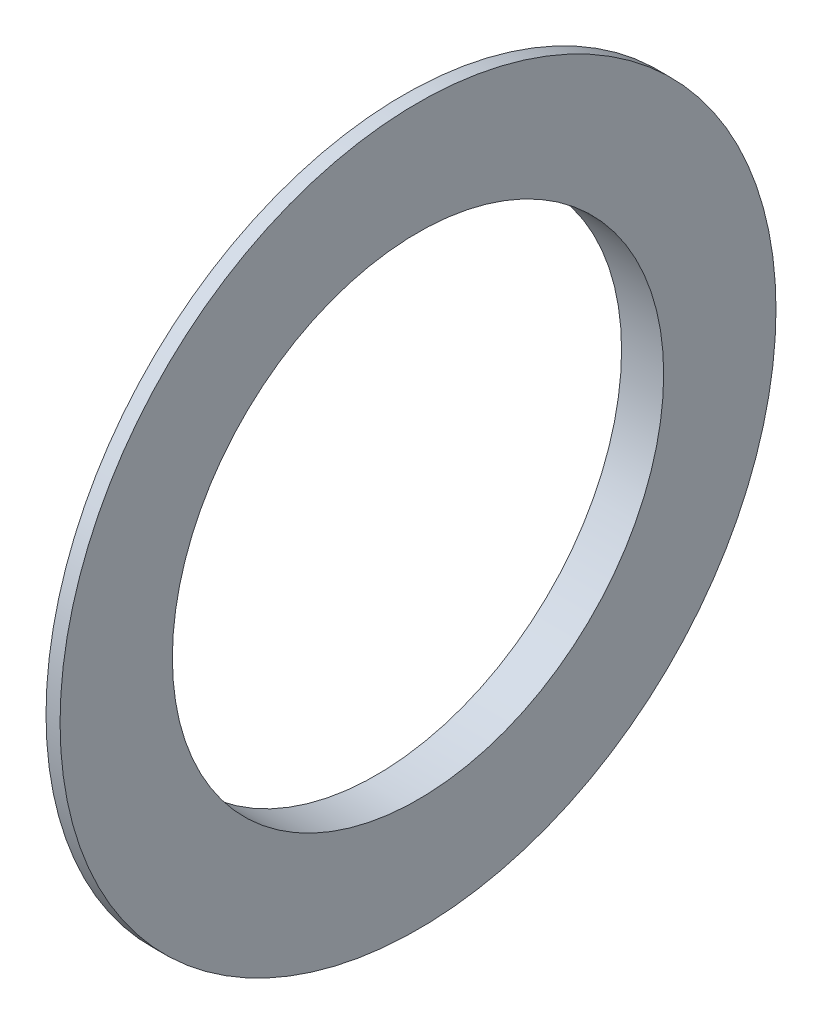
from build123d import *


with BuildPart() as part:
    # Szkic1 → Obrót1 (revolve)
    with BuildSketch(Plane.XY):
        Polygon((86.751162791, 19.063636364), (86.751162791, 17.5), (89.751162791, 17.5), (89.751162791, 25.5), (88.751162791, 25.5), align=None)
    revolve(axis=Axis((0, 0, 0), (1, 0, 0)))


solid = part.part
